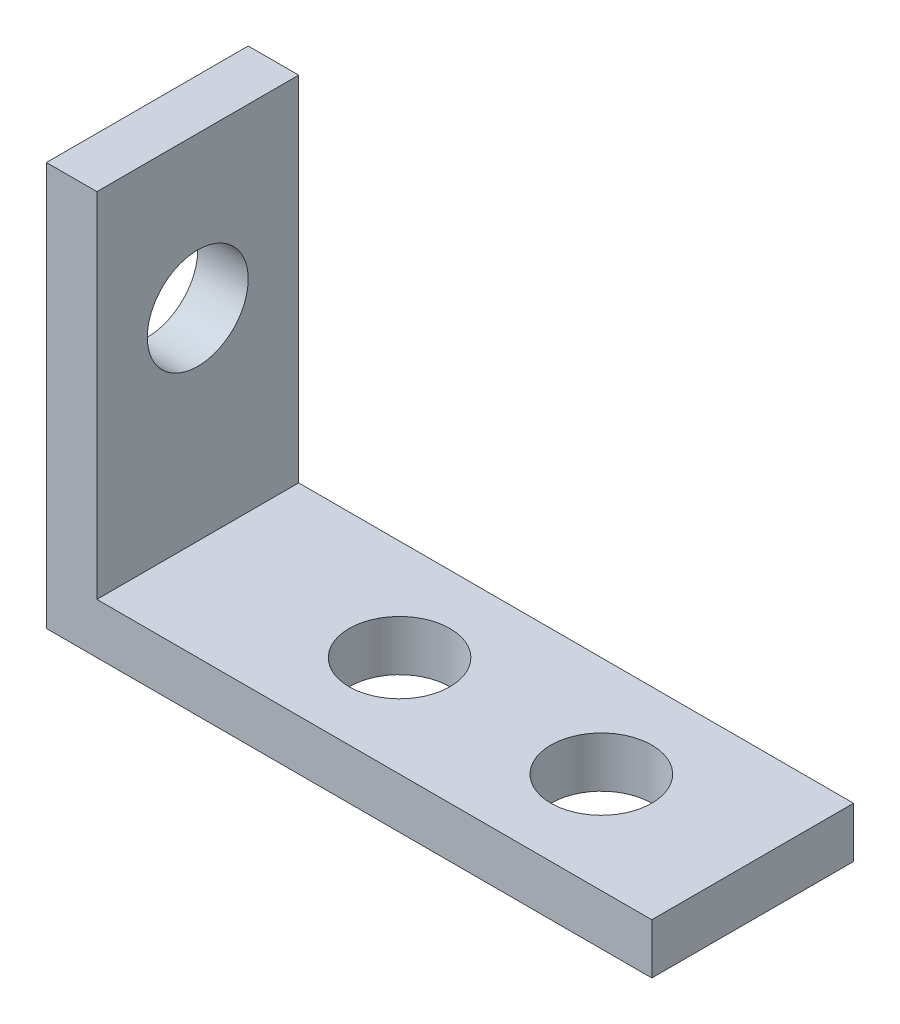
from build123d import *

# Parameters (mm, degrees)
BOSS_EXTRUDE1_DEPTH = 12.7
SKETCH2_R           = 3.175
CUT_EXTRUDE1_DEPTH  = 4.175
SKETCH3_R           = 3.175
CUT_EXTRUDE2_DEPTH  = 4.175


with BuildPart() as part:
    # Sketch1 → Boss-Extrude1 (new body)
    with BuildSketch(Plane.XY):
        Polygon((0, 0), (0, 25.4), (3.175, 25.4), (3.175, 3.175), (38.1, 3.175), (38.1, 0), align=None)
    extrude(amount=BOSS_EXTRUDE1_DEPTH)

    # Sketch2 → Cut-Extrude1 (cut, through all)
    with BuildSketch(Plane(origin=(0, 3.175, 0), x_dir=(1, 0, 0), z_dir=(0, 1, 0))):
        with Locations((15.875, -6.35)):
            Circle(SKETCH2_R)
        with Locations((28.575, -6.35)):
            Circle(SKETCH2_R)
    extrude(amount=-CUT_EXTRUDE1_DEPTH, mode=Mode.SUBTRACT)

    # Sketch3 → Cut-Extrude2 (cut, through all)
    with BuildSketch(Plane(origin=(3.175, 0, 0), x_dir=(0, 0, -1), z_dir=(1, 0, 0))):
        with Locations((-6.35, 28.575)):
            Circle(SKETCH3_R)
        with Locations((-6.35, 15.875)):
            Circle(SKETCH3_R)
    extrude(amount=-CUT_EXTRUDE2_DEPTH, mode=Mode.SUBTRACT)


solid = part.part
